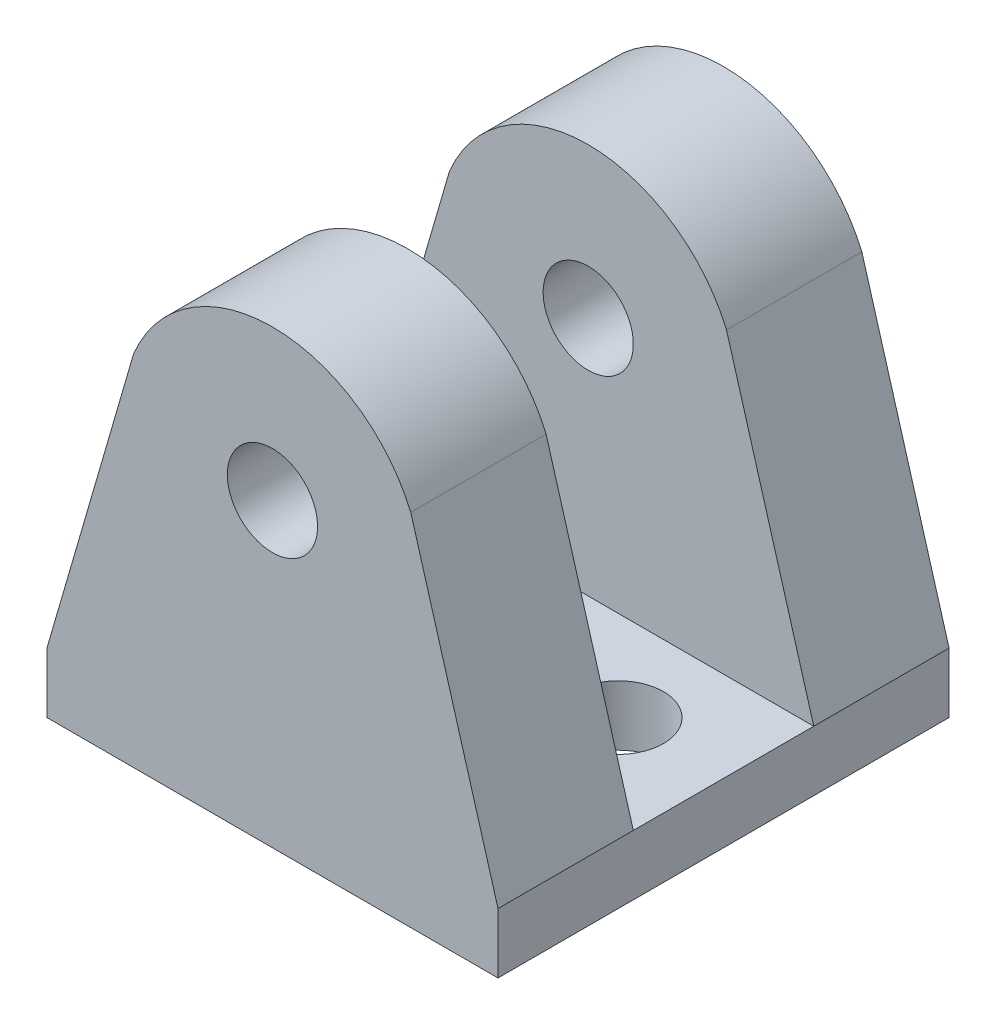
from build123d import *

# Parameters (mm, degrees)
SKETCH7_W           = 15
SKETCH7_H           = 7.5
BOSS_EXTRUDE2_DEPTH = 2
SKETCH8_R           = 1.5
BOSS_EXTRUDE3_DEPTH = 4.5
SKETCH9_R           = 1.5
CUT_EXTRUDE1_DEPTH  = 3


with BuildPart() as part:
    # Sketch7 → Boss-Extrude2 (new body)
    with BuildSketch(Plane(origin=(0, 0, 0), x_dir=(1, 0, 0), z_dir=(0, 1, 0))):
        with Locations((0, -3.75)):
            Rectangle(SKETCH7_W, SKETCH7_H)
    boss_extrude2 = extrude(amount=BOSS_EXTRUDE2_DEPTH)

    # Sketch8 → Boss-Extrude3 (add)
    with BuildSketch(Plane(origin=(0, 0, 0), x_dir=(-1, 0, 0), z_dir=(0, 0, -1))):
        with BuildLine():
            Line((-4.598991345, 11.961957852), (-7.5, 2))
            Line((-7.5, 2), (7.5, 2))
            Line((7.5, 2), (4.615024569, 11.923940807))
            ThreePointArc((4.615024569, 11.923940807), (0.020629833, 14.999957441), (-4.598991345, 11.961957852))
        make_face()
        with Locations((0, 10)):
            Circle(SKETCH8_R, mode=Mode.SUBTRACT)
    boss_extrude3 = extrude(amount=-BOSS_EXTRUDE3_DEPTH)

    # Mirror1: Boss-Extrude2, Boss-Extrude3 across plane
    add(boss_extrude2.mirror(Plane(origin=(7.5, 2, 7.5), x_dir=(1, 0, 0), z_dir=(0, 0, -1))))
    add(boss_extrude3.mirror(Plane(origin=(7.5, 2, 7.5), x_dir=(1, 0, 0), z_dir=(0, 0, -1))))

    # Sketch9 → Cut-Extrude1 (cut, through all)
    with BuildSketch(Plane(origin=(0, 2, 0), x_dir=(1, 0, 0), z_dir=(0, 1, 0))):
        with Locations((4, -7.5)):
            Circle(SKETCH9_R)
    cut_extrude1 = extrude(amount=-CUT_EXTRUDE1_DEPTH, mode=Mode.SUBTRACT)

    # Mirror2: Cut-Extrude1 across plane
    add(cut_extrude1.mirror(Plane(origin=(0, 0, 0), x_dir=(0, 0, 1), z_dir=(1, 0, 0))), mode=Mode.SUBTRACT)


solid = part.part
